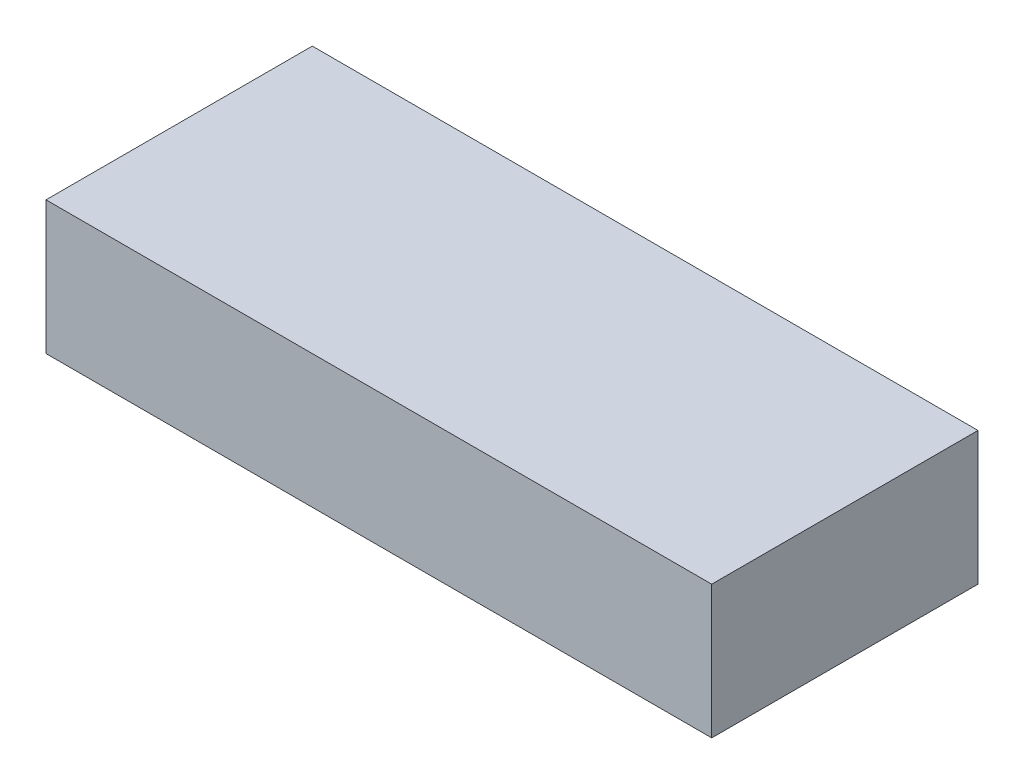
from build123d import *

# Parameters (mm, degrees)
SKETCH1_W           = 30
SKETCH1_H           = 12
BOSS_EXTRUDE1_DEPTH = 6


with BuildPart() as part:
    # Sketch1 → Boss-Extrude1 (new body)
    with BuildSketch(Plane(origin=(0, 0, 0), x_dir=(1, 0, 0), z_dir=(0, 1, 0))):
        Rectangle(SKETCH1_W, SKETCH1_H)
    extrude(amount=BOSS_EXTRUDE1_DEPTH)


solid = part.part
